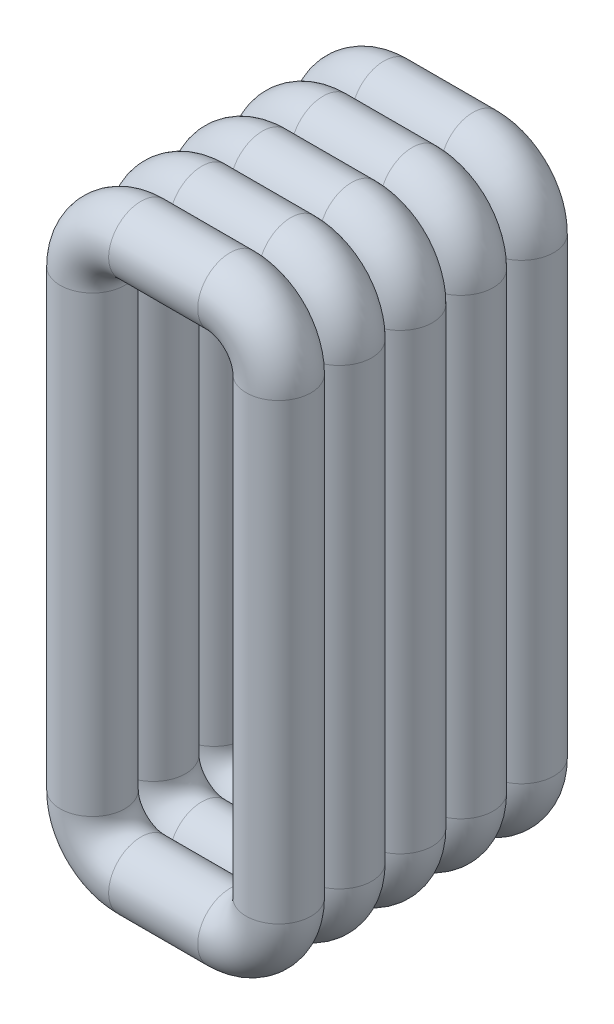
from build123d import *

# Parameters (mm, degrees)
ESQUISSE2_R                = 0.4
R_P_TITION_LIN_AIRE1_COUNT = 5
R_P_TITION_LIN_AIRE1_PITCH = 0.75


with BuildPart() as part:
    # Balayage1: sweep along a path in Esquisse3
    with BuildLine(Plane.XY) as balayage1_path:
        Line((0.55, -3), (-0.55, -3))
        ThreePointArc((-0.55, -3), (-0.691421356, -2.941421356), (-0.75, -2.8))
        Line((-0.75, -2.8), (-0.75, 2.8))
        ThreePointArc((-0.75, 2.8), (-0.691421356, 2.941421356), (-0.55, 3))
        Line((-0.55, 3), (0.55, 3))
        ThreePointArc((0.55, 3), (0.691421356, 2.941421356), (0.75, 2.8))
        Line((0.75, 2.8), (0.75, -2.8))
        ThreePointArc((0.75, -2.8), (0.691421356, -2.941421356), (0.55, -3))
    # Esquisse2 → Balayage1 (sweep)
    with BuildSketch(Plane(origin=(0, 0, 0), x_dir=(0, 0, -1), z_dir=(1, 0, 0))):
        with Locations((0, 3.4)):
            Circle(ESQUISSE2_R)
    balayage1 = sweep(path=balayage1_path.line)

    # Répétition linéaire1: Balayage1 ×5
    with Locations(*[(0, 0, i * R_P_TITION_LIN_AIRE1_PITCH) for i in range(1, R_P_TITION_LIN_AIRE1_COUNT)]):
        add(balayage1)


solid = part.part
